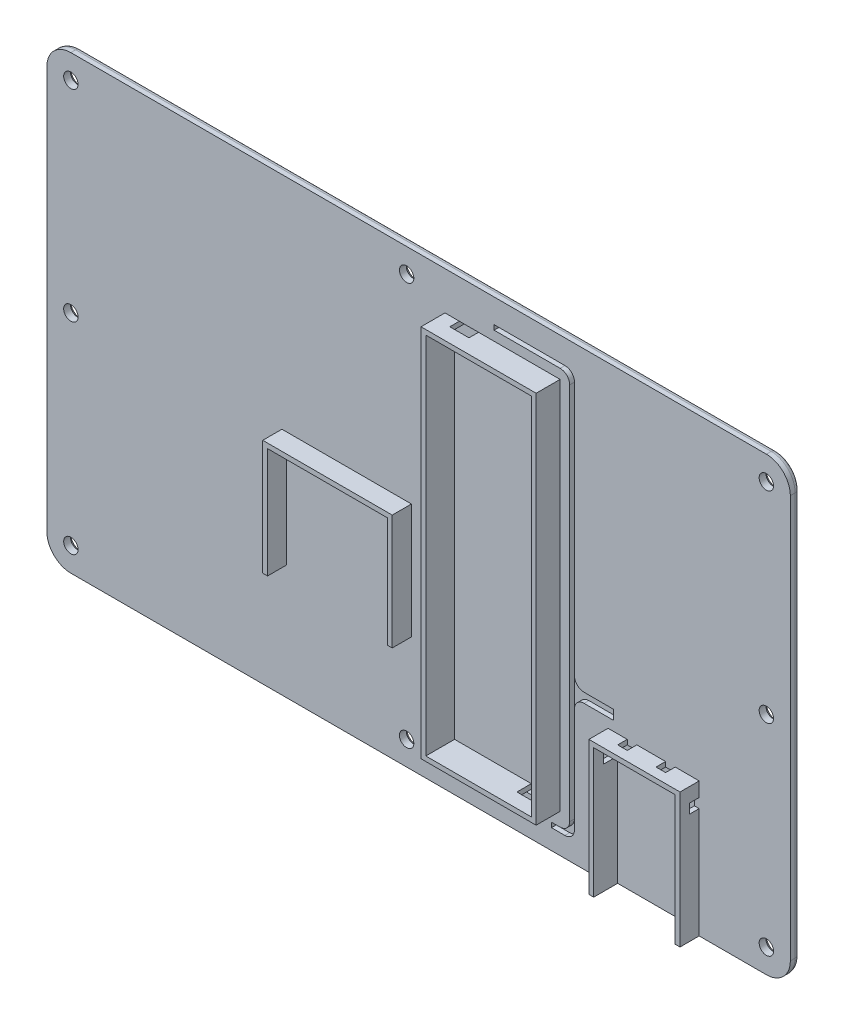
from build123d import *

# Parameters (mm, degrees)
BOSS_EXTRUDE1_DEPTH                           = 2
CSK_FOR_0_FLAT_HEAD_MACHINE_SCREW1_AT_2_COUNT = 2
CSK_FOR_0_FLAT_HEAD_MACHINE_SCREW1_AT_2_PITCH = 42
CSK_FOR_0_FLAT_HEAD_MACHINE_SCREW1_AT_3_COUNT = 2
CSK_FOR_0_FLAT_HEAD_MACHINE_SCREW1_AT_3_PITCH = 84
CSK_FOR_0_FLAT_HEAD_MACHINE_SCREW1_AT_4_COUNT = 2
CSK_FOR_0_FLAT_HEAD_MACHINE_SCREW1_AT_4_PITCH = 112.609946275
CSK_FOR_0_FLAT_HEAD_MACHINE_SCREW1_AT_5_COUNT = 2
CSK_FOR_0_FLAT_HEAD_MACHINE_SCREW1_AT_5_PITCH = 167.573864311
CSK_FOR_0_FLAT_HEAD_MACHINE_SCREW1_AT_6_COUNT = 2
CSK_FOR_0_FLAT_HEAD_MACHINE_SCREW1_AT_6_PITCH = 150.960259671
CSK_FOR_0_FLAT_HEAD_MACHINE_SCREW1_AT_7_COUNT = 2
CSK_FOR_0_FLAT_HEAD_MACHINE_SCREW1_AT_7_PITCH = 145
CSK_FOR_0_FLAT_HEAD_MACHINE_SCREW1_AT_8_COUNT = 2
CSK_FOR_0_FLAT_HEAD_MACHINE_SCREW1_AT_8_PITCH = 75
FILLET1_R                                     = 1
SKETCH9_W                                     = 22
SKETCH9_H                                     = 76
CUT_EXTRUDE2_DEPTH                            = 1
SKETCH9_5_W                                   = 24
SKETCH9_5_H                                   = 78
SKETCH9_5_W_2                                 = 22
SKETCH9_5_H_2                                 = 76
BOSS_EXTRUDE4_DEPTH                           = 5
SKETCH11_W                                    = 4
SKETCH11_H                                    = 2
CUT_EXTRUDE4_DEPTH                            = 5
SKETCH13_W                                    = 4
SKETCH13_H                                    = 2
CUT_EXTRUDE5_DEPTH                            = 1
SKETCH14_W                                    = 4
SKETCH14_H                                    = 1
CUT_EXTRUDE6_DEPTH                            = 1
SKETCH15_W                                    = 4
SKETCH15_H                                    = 1
CUT_EXTRUDE7_DEPTH                            = 1
BOSS_EXTRUDE5_DEPTH                           = 4
SKETCH9_8_W                                   = 17
SKETCH9_8_H                                   = 27
CUT_EXTRUDE10_DEPTH                           = 1
SKETCH17_W                                    = 2
SKETCH17_H                                    = 2
CUT_EXTRUDE11_DEPTH                           = 1
CUT_EXTRUDE12_DEPTH                           = 21
CUT_EXTRUDE12_DEPTH_BACK                      = 1
SKETCH18_W                                    = 2
SKETCH18_H                                    = 2
CUT_EXTRUDE13_DEPTH                           = 1
BOSS_EXTRUDE6_DEPTH                           = 4


with BuildPart() as part:
    # Sketch1 → Boss-Extrude1 (new body)
    with BuildSketch(Plane.XY):
        with BuildLine():
            Line((-70, 47), (75, 47))
            ThreePointArc((75, 47), (78.535533906, 45.535533906), (80, 42))
            Line((80, 42), (80, -42))
            ThreePointArc((80, -42), (78.535533906, -45.535533906), (75, -47))
            Line((75, -47), (-70, -47))
            ThreePointArc((-70, -47), (-73.535533906, -45.535533906), (-75, -42))
            Line((-75, -42), (-75, 42))
            ThreePointArc((-75, 42), (-73.535533906, 45.535533906), (-70, 47))
        make_face()
    extrude(amount=BOSS_EXTRUDE1_DEPTH)

    # Sketch8 → CSK for _0 Flat Head Machine Screw1 (revolve, cut)
    with BuildSketch(Plane(origin=(75, 42, 0), x_dir=(0, 1, 0), z_dir=(1, 0, 0))):
        Polygon((0, 0), (0, 2), (1.500000048, 2), (1.500000048, 0.575184076), (1.999999937, 0), align=None)
    csk_for_0_flat_head_machine_screw1 = revolve(axis=Axis((75, 42, -6.35), (0, 0, 1)), mode=Mode.SUBTRACT)

    # CSK for _0 Flat Head Machine Screw1 at 2: CSK for _0 Flat Head Machine Screw1 ×2
    with Locations(*[(0, -i * CSK_FOR_0_FLAT_HEAD_MACHINE_SCREW1_AT_2_PITCH, 0) for i in range(1, CSK_FOR_0_FLAT_HEAD_MACHINE_SCREW1_AT_2_COUNT)]):
        add(csk_for_0_flat_head_machine_screw1, mode=Mode.SUBTRACT)

    # CSK for _0 Flat Head Machine Screw1 at 3: CSK for _0 Flat Head Machine Screw1 ×2
    with Locations(*[(0, -i * CSK_FOR_0_FLAT_HEAD_MACHINE_SCREW1_AT_3_PITCH, 0) for i in range(1, CSK_FOR_0_FLAT_HEAD_MACHINE_SCREW1_AT_3_COUNT)]):
        add(csk_for_0_flat_head_machine_screw1, mode=Mode.SUBTRACT)

    # CSK for _0 Flat Head Machine Screw1 at 4: CSK for _0 Flat Head Machine Screw1 ×2
    with Locations(*[Vector(-0.6660157693088523, -0.7459376616259147, 0) * (i * CSK_FOR_0_FLAT_HEAD_MACHINE_SCREW1_AT_4_PITCH) for i in range(1, CSK_FOR_0_FLAT_HEAD_MACHINE_SCREW1_AT_4_COUNT)]):
        add(csk_for_0_flat_head_machine_screw1, mode=Mode.SUBTRACT)

    # CSK for _0 Flat Head Machine Screw1 at 5: CSK for _0 Flat Head Machine Screw1 ×2
    with Locations(*[Vector(-0.8652900653481878, -0.5012714861327433, 0) * (i * CSK_FOR_0_FLAT_HEAD_MACHINE_SCREW1_AT_5_PITCH) for i in range(1, CSK_FOR_0_FLAT_HEAD_MACHINE_SCREW1_AT_5_COUNT)]):
        add(csk_for_0_flat_head_machine_screw1, mode=Mode.SUBTRACT)

    # CSK for _0 Flat Head Machine Screw1 at 6: CSK for _0 Flat Head Machine Screw1 ×2
    with Locations(*[Vector(-0.9605176906545201, -0.27821891729303344, 0) * (i * CSK_FOR_0_FLAT_HEAD_MACHINE_SCREW1_AT_6_PITCH) for i in range(1, CSK_FOR_0_FLAT_HEAD_MACHINE_SCREW1_AT_6_COUNT)]):
        add(csk_for_0_flat_head_machine_screw1, mode=Mode.SUBTRACT)

    # CSK for _0 Flat Head Machine Screw1 at 7: CSK for _0 Flat Head Machine Screw1 ×2
    with Locations(*[(-i * CSK_FOR_0_FLAT_HEAD_MACHINE_SCREW1_AT_7_PITCH, 0, 0) for i in range(1, CSK_FOR_0_FLAT_HEAD_MACHINE_SCREW1_AT_7_COUNT)]):
        add(csk_for_0_flat_head_machine_screw1, mode=Mode.SUBTRACT)

    # CSK for _0 Flat Head Machine Screw1 at 8: CSK for _0 Flat Head Machine Screw1 ×2
    with Locations(*[(-i * CSK_FOR_0_FLAT_HEAD_MACHINE_SCREW1_AT_8_PITCH, 0, 0) for i in range(1, CSK_FOR_0_FLAT_HEAD_MACHINE_SCREW1_AT_8_COUNT)]):
        add(csk_for_0_flat_head_machine_screw1, mode=Mode.SUBTRACT)

    # Fillet1
    fillet1_edges = [part.edges().sort_by_distance(p)[0] for p in [
        (78.535533906, 45.535533906, 0),
        (80, 0, 0),
        (78.535533906, -45.535533906, 0),
        (2.5, -47, 0),
        (-73.535533906, -45.535533906, 0),
        (-75, 0, 0),
        (-73.535533906, 45.535533906, 0),
        (2.5, 47, 0),
    ]]
    fillet(fillet1_edges, radius=FILLET1_R)

    # Sketch9 → Cut-Extrude2 (cut)
    with BuildSketch(Plane.XY.offset(2)):
        with Locations((20, 0)):
            Rectangle(SKETCH9_W, SKETCH9_H)
    extrude(amount=-CUT_EXTRUDE2_DEPTH, mode=Mode.SUBTRACT)

    # Sketch9_5 → Boss-Extrude4 (add)
    with BuildSketch(Plane.XY.offset(2)):
        with Locations((20, 0)):
            Rectangle(SKETCH9_5_W, SKETCH9_5_H)
        with Locations((20, 0)):
            Rectangle(SKETCH9_5_W_2, SKETCH9_5_H_2, mode=Mode.SUBTRACT)
    extrude(amount=BOSS_EXTRUDE4_DEPTH)

    # Sketch11 → Cut-Extrude4 (cut)
    with BuildSketch(Plane(origin=(0, 39, 0), x_dir=(1, 0, 0), z_dir=(0, 1, 0))):
        with Locations((13, -3)):
            Rectangle(SKETCH11_W, SKETCH11_H)
    extrude(amount=-CUT_EXTRUDE4_DEPTH, mode=Mode.SUBTRACT)

    # Sketch13 → Cut-Extrude5 (cut)
    with BuildSketch(Plane.XZ.offset(39)):
        with Locations((27, 3)):
            Rectangle(SKETCH13_W, SKETCH13_H)
    extrude(amount=-CUT_EXTRUDE5_DEPTH, mode=Mode.SUBTRACT)

    # Sketch14 → Cut-Extrude6 (cut)
    with BuildSketch(Plane.XZ.offset(-38)):
        with Locations((13, 1.5)):
            Rectangle(SKETCH14_W, SKETCH14_H)
    extrude(amount=-CUT_EXTRUDE6_DEPTH, mode=Mode.SUBTRACT)

    # Sketch15 → Cut-Extrude7 (cut)
    with BuildSketch(Plane(origin=(0, -38, 0), x_dir=(1, 0, 0), z_dir=(0, 1, 0))):
        with Locations((27, -1.5)):
            Rectangle(SKETCH15_W, SKETCH15_H)
    extrude(amount=-CUT_EXTRUDE7_DEPTH, mode=Mode.SUBTRACT)

    # Sketch9_7 → Boss-Extrude5 (add)
    with BuildSketch(Plane.XY.offset(2)):
        Polygon((42, -47), (43, -47), (43, -20), (60, -20), (60, -47), (61, -47), (61, -19), (42, -19), align=None)
    extrude(amount=BOSS_EXTRUDE5_DEPTH)

    # Sketch9_8 → Cut-Extrude10 (cut)
    with BuildSketch(Plane.XY.offset(2)):
        with Locations((51.5, -33.5)):
            Rectangle(SKETCH9_8_W, SKETCH9_8_H)
    extrude(amount=-CUT_EXTRUDE10_DEPTH, mode=Mode.SUBTRACT)

    # Sketch17 → Cut-Extrude11 (cut)
    with BuildSketch(Plane.XZ.offset(20)):
        with Locations((47, 3)):
            Rectangle(SKETCH17_W, SKETCH17_H)
        with Locations((55, 3)):
            Rectangle(SKETCH17_W, SKETCH17_H)
    extrude(amount=-CUT_EXTRUDE11_DEPTH, mode=Mode.SUBTRACT)

    # Sketch18 → Cut-Extrude12 (cut, two sides: drawn at the far end of the back side and taken through both)
    with BuildSketch(Plane.ZY.offset(-60).offset(-CUT_EXTRUDE12_DEPTH_BACK)):
        with Locations((3, -23)):
            Rectangle(SKETCH18_W, SKETCH18_H)
    extrude(amount=CUT_EXTRUDE12_DEPTH + CUT_EXTRUDE12_DEPTH_BACK, mode=Mode.SUBTRACT)

    # Sketch19 → Cut-Extrude13 (cut)
    with BuildSketch(Plane.XY.offset(2)):
        with BuildLine():
            Line((32, -41.849789893), (30.191318858, -41.849789893))
            Line((30.191318858, -41.849789893), (30.191318858, -42.849789893))
            Line((30.191318858, -42.849789893), (33, -42.849789893))
            ThreePointArc((33, -42.849789893), (34.414213562, -42.264003455), (35, -40.849789893))
            Line((35, -40.849789893), (35, -19))
            ThreePointArc((35, -19), (35.585786438, -17.585786438), (37, -17))
            Line((37, -17), (43.101704987, -17))
            Line((43.101704987, -17), (43.101704987, -16))
            Line((43.101704987, -16), (43.101704987, -15))
            Line((43.101704987, -15), (37, -15))
            ThreePointArc((37, -15), (35.585786438, -14.414213562), (35, -13))
            Line((35, -13), (35, 40))
            ThreePointArc((35, 40), (34.414213562, 41.414213562), (33, 42))
            Line((33, 42), (18.235350669, 42))
            Line((18.235350669, 42), (18.235350669, 41))
            Line((18.235350669, 41), (32, 41))
            ThreePointArc((32, 41), (33.414213562, 40.414213562), (34, 39))
            Line((34, 39), (34, -16))
            Line((34, -16), (34, -39.849789893))
            ThreePointArc((34, -39.849789893), (33.414213562, -41.264003455), (32, -41.849789893))
        make_face()
    extrude(amount=-CUT_EXTRUDE13_DEPTH, mode=Mode.SUBTRACT)

    # Sketch20 → Boss-Extrude6 (add)
    with BuildSketch(Plane.XY.offset(2)):
        Polygon((0, 0), (0, -23), (1, -23), (1, 1), (-26, 1), (-26, -23), (-25, -23), (-25, 0), align=None)
    extrude(amount=BOSS_EXTRUDE6_DEPTH)


solid = part.part
